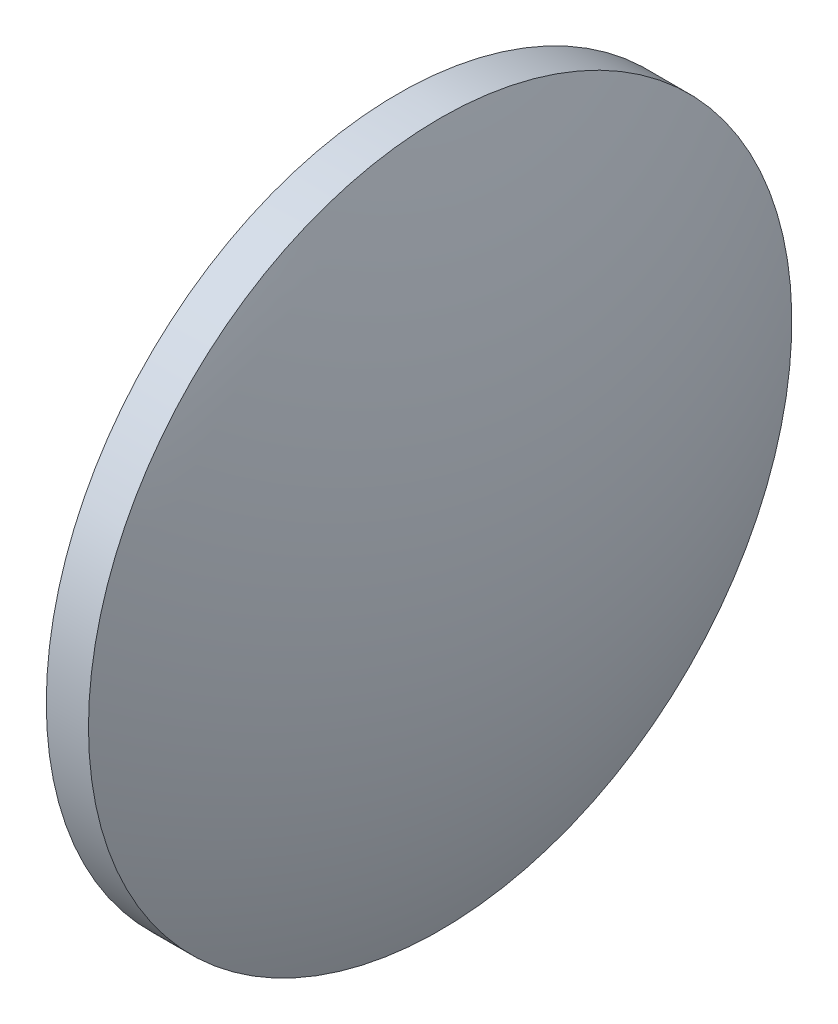
from build123d import *


with BuildPart() as part:
    # 草图2 → 旋转2 (revolve)
    with BuildSketch(Plane.XY):
        with BuildLine():
            Line((668.04887257, 221.711816188), (668.04887257, 234.211816188))
            Line((668.04887257, 234.211816188), (669.54887257, 234.211816188))
            ThreePointArc((669.54887257, 234.211816188), (671.41774453, 228.08559058), (672.04887257, 221.711816188))
            Line((672.04887257, 221.711816188), (668.04887257, 221.711816188))
        make_face()
    revolve(axis=Axis((644.580747603, 221.711816188, 0), (1, 0, 0)))


solid = part.part
